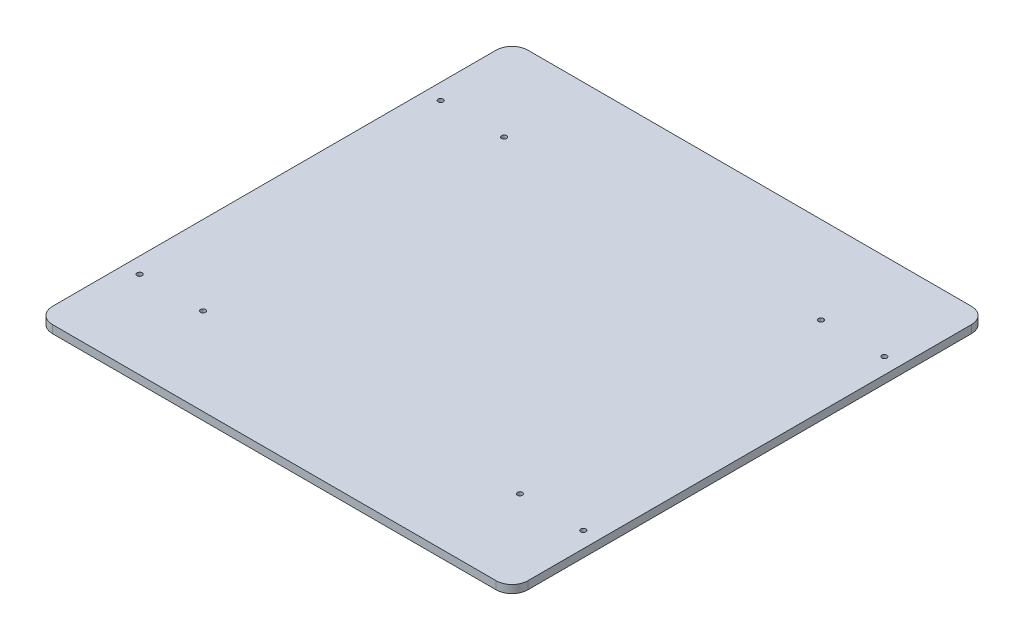
from build123d import *

# Parameters (mm, degrees)
ESQUISSE1_W                     = 300
ESQUISSE1_H                     = 300
BOSS_EXTRU_1_DEPTH              = 5
CONG_1_R                        = 10
ESQUISSE2_R                     = 1.6
ENL_V_MAT_EXTRU_1_DEPTH         = 6
R_P_TITION_LIN_AIRE1_COUNT      = 2
R_P_TITION_LIN_AIRE1_PITCH      = 240
R_P_TITION_LIN_AIRE1_COUNT_DIR2 = 2
R_P_TITION_LIN_AIRE1_PITCH_DIR2 = 190


with BuildPart() as part:
    # Esquisse1 → Boss.-Extru.1 (new body)
    with BuildSketch(Plane(origin=(0, 0, 0), x_dir=(1, 0, 0), z_dir=(0, 1, 0))):
        Rectangle(ESQUISSE1_W, ESQUISSE1_H)
    extrude(amount=BOSS_EXTRU_1_DEPTH)

    # Congé1
    cong_1_edges = [part.edges().sort_by_distance(p)[0] for p in [
        (150, 2.5, 150),
        (-150, 2.5, 150),
        (-150, 2.5, -150),
        (150, 2.5, -150),
    ]]
    fillet(cong_1_edges, radius=CONG_1_R)

    # Esquisse2 → Enlèv. mat.-Extru.1 (cut, through all)
    with BuildSketch(Plane.XZ):
        with Locations((-140, 95)):
            Circle(ESQUISSE2_R)
        with Locations((-100, 95)):
            Circle(ESQUISSE2_R)
    enl_v_mat_extru_1 = extrude(amount=-ENL_V_MAT_EXTRU_1_DEPTH, mode=Mode.SUBTRACT)

    # Répétition linéaire1: Enl_v. mat.-Extru.1 2 × 2
    with Locations(*[(i * R_P_TITION_LIN_AIRE1_PITCH, 0, -j * R_P_TITION_LIN_AIRE1_PITCH_DIR2) for i in range(R_P_TITION_LIN_AIRE1_COUNT) for j in range(R_P_TITION_LIN_AIRE1_COUNT_DIR2) if (i, j) != (0, 0)]):
        add(enl_v_mat_extru_1, mode=Mode.SUBTRACT)


solid = part.part
